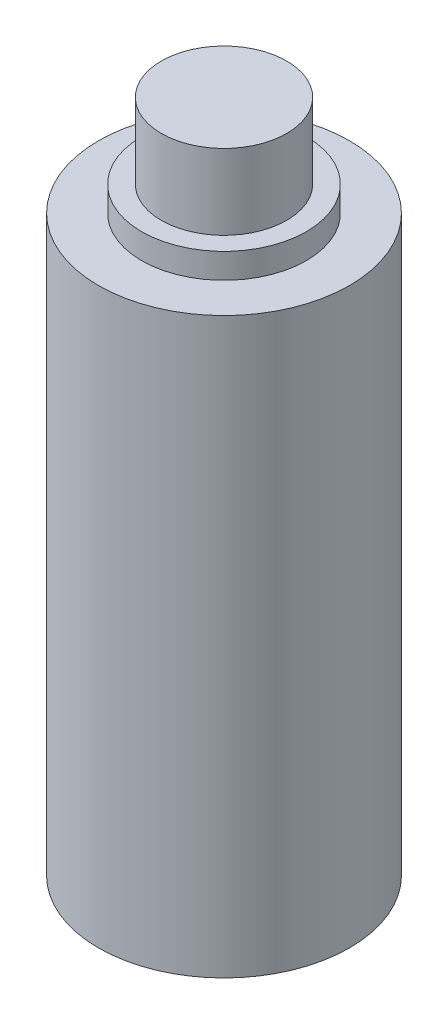
from build123d import *

# Parameters (mm, degrees)
SKETCH1_R           = 4
BOSS_EXTRUDE1_DEPTH = 18.288
SKETCH2_R           = 2.625
BOSS_EXTRUDE2_DEPTH = 0.8
SKETCH3_R           = 2
BOSS_EXTRUDE3_DEPTH = 2.4


with BuildPart() as part:
    # Sketch1 → Boss-Extrude1 (new body)
    with BuildSketch(Plane(origin=(0, 0, 0), x_dir=(1, 0, 0), z_dir=(0, 1, 0))):
        Circle(SKETCH1_R)
    extrude(amount=BOSS_EXTRUDE1_DEPTH)

    # Sketch2 → Boss-Extrude2 (add)
    with BuildSketch(Plane(origin=(0, 18.288, 0), x_dir=(1, 0, 0), z_dir=(0, 1, 0))):
        Circle(SKETCH2_R)
    extrude(amount=BOSS_EXTRUDE2_DEPTH)

    # Sketch3 → Boss-Extrude3 (add)
    with BuildSketch(Plane(origin=(0, 19.088, 0), x_dir=(1, 0, 0), z_dir=(0, 1, 0))):
        Circle(SKETCH3_R)
    extrude(amount=BOSS_EXTRUDE3_DEPTH)


solid = part.part
